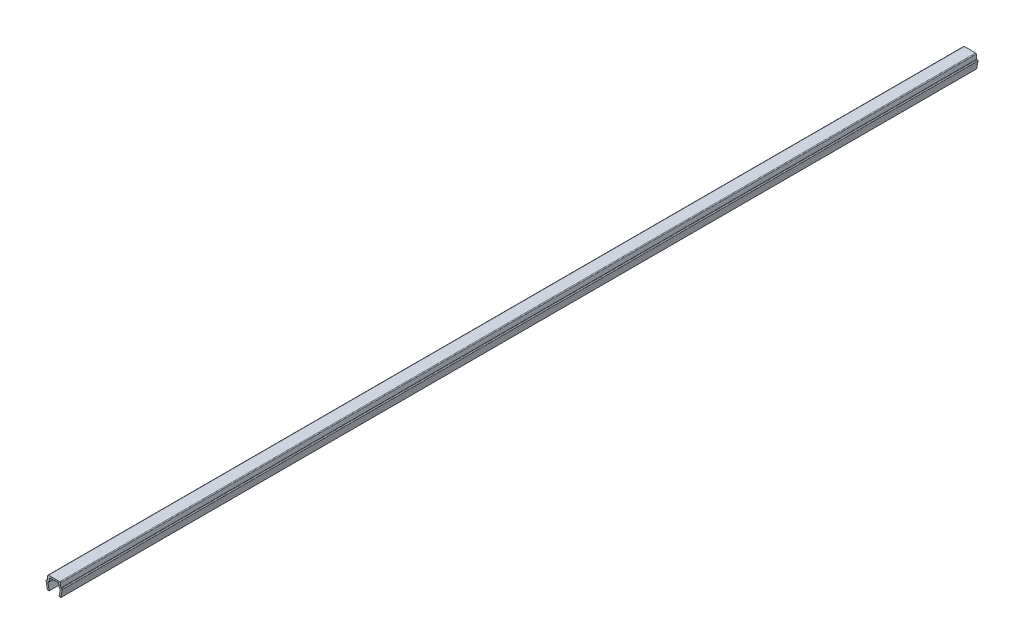
from build123d import *

# Parameters (mm, degrees)
BOSS_EXTRUDE1_DEPTH = 203.75


with BuildPart() as part:
    # Sketch1 → Boss-Extrude1 (new body, symmetric)
    with BuildSketch(Plane.XY):
        with BuildLine():
            Line((-3.6, 3.35), (-3, 0))
            Line((-3, 0), (-2.2, 0))
            Line((-2.2, 0), (-2.735217071, 2.988295315))
            ThreePointArc((-2.735217071, 2.988295315), (-2.659117427, 3.274614514), (-2.390699246, 3.4))
            Line((-2.390699246, 3.4), (-2.2, 3.4))
            Line((-2.2, 3.4), (-2.070472639, 4.88050451))
            ThreePointArc((-2.070472639, 4.88050451), (-1.958261067, 5.108047068), (-1.721804495, 5.2))
            Line((-1.721804495, 5.2), (1.721804495, 5.2))
            ThreePointArc((1.721804495, 5.2), (1.958261067, 5.108047068), (2.070472639, 4.88050451))
            Line((2.070472639, 4.88050451), (2.2, 3.4))
            Line((2.2, 3.4), (2.390699246, 3.4))
            ThreePointArc((2.390699246, 3.4), (2.659117427, 3.274614514), (2.735217071, 2.988295315))
            Line((2.735217071, 2.988295315), (2.2, 0))
            Line((2.2, 0), (3, 0))
            Line((3, 0), (3.6, 3.35))
            ThreePointArc((3.6, 3.35), (3.497487373, 3.597487373), (3.25, 3.7))
            Line((3.25, 3.7), (3, 3.7))
            Line((3, 3.7), (2.835477174, 5.58050451))
            ThreePointArc((2.835477174, 5.58050451), (2.723265602, 5.808047068), (2.486809029, 5.9))
            Line((2.486809029, 5.9), (-2.486809029, 5.9))
            ThreePointArc((-2.486809029, 5.9), (-2.723265602, 5.808047068), (-2.835477174, 5.58050451))
            Line((-2.835477174, 5.58050451), (-3, 3.7))
            Line((-3, 3.7), (-3.25, 3.7))
            ThreePointArc((-3.25, 3.7), (-3.497487373, 3.597487373), (-3.6, 3.35))
        make_face()
    extrude(amount=BOSS_EXTRUDE1_DEPTH, both=True)


solid = part.part
